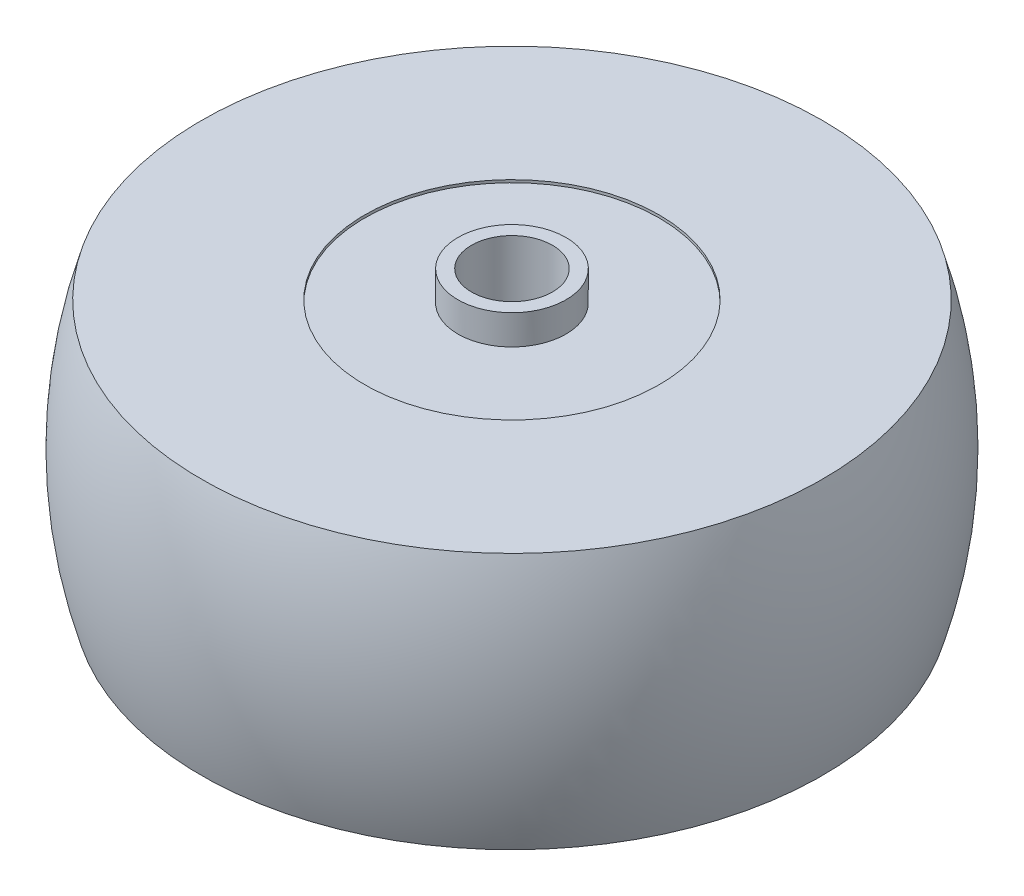
from build123d import *

# Parameters (mm, degrees)
SKETCH2_W = 1
SKETCH2_H = 2.2


with BuildPart() as part:
    # Sketch1 → Revolve1 (revolve)
    with BuildSketch(Plane(origin=(0, 0, 0), x_dir=(0, 0, -1), z_dir=(1, 0, 0))):
        with BuildLine():
            Line((3, -9.3), (3, 9.3))
            Line((3, 9.3), (10.9, 9.3))
            Line((10.9, 9.3), (10.9, 9.5))
            Line((10.9, 9.5), (23, 9.5))
            ThreePointArc((23, 9.5), (24.4, 0), (23, -9.5))
            Line((23, -9.5), (10.9, -9.5))
            Line((10.9, -9.5), (10.9, -9.3))
            Line((10.9, -9.3), (3, -9.3))
        make_face()
    revolve(axis=Axis((0, 0, 0), (0, 1, 0)))

    # Sketch2 → Revolve2 (revolve)
    with BuildSketch(Plane.XY, mode=Mode.PRIVATE) as revolve2_sk:
        with Locations((3.5, 10.4)):
            Rectangle(SKETCH2_W, SKETCH2_H)
        with Locations((3.5, -10.4)):
            Rectangle(SKETCH2_W, SKETCH2_H)
    revolve(revolve2_sk.sketch.rotate(Axis((0, 0, 0), (0, 1, 0)), 90), axis=Axis((0, 0, 0), (0, 1, 0)))


solid = part.part
